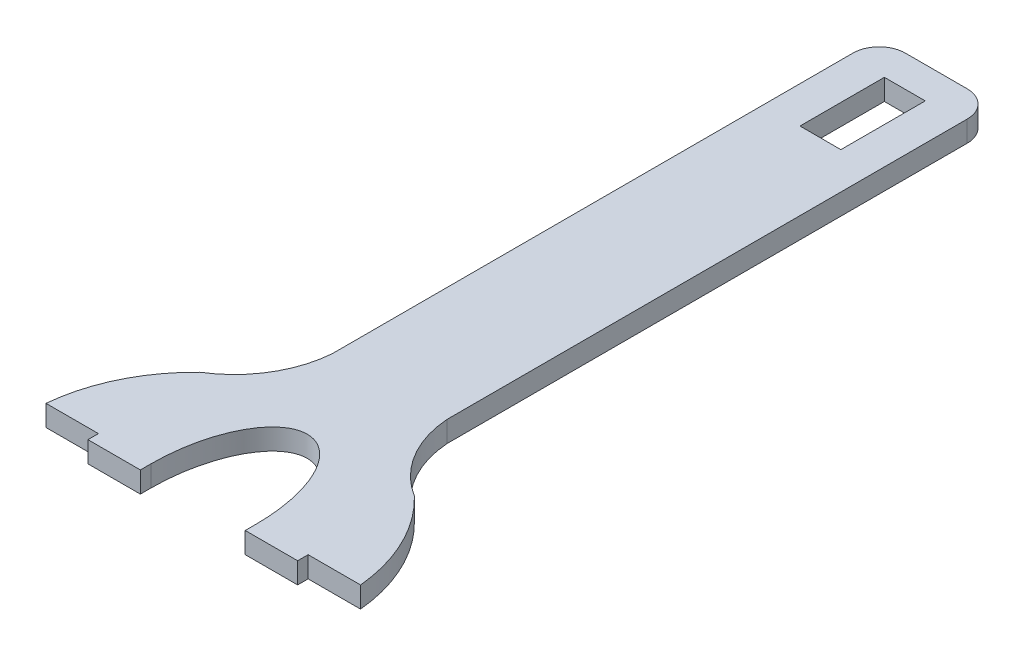
from build123d import *

# Parameters (mm, degrees)
BOSS_EXTRUDE1_DEPTH = 10.16
SKETCH2_W           = 19.812
SKETCH2_H           = 40.894
CUT_EXTRUDE1_DEPTH  = 11.1600001


with BuildPart() as part:
    # Sketch1 → Boss-Extrude1 (new body)
    with BuildSketch(Plane(origin=(0, 0, 0), x_dir=(1, 0, 0), z_dir=(0, 1, 0))):
        with BuildLine():
            Line((0, 0), (25.4, 0))
            Line((25.4, 0), (25.4, -5.08))
            Line((25.4, -5.08), (50.8, -5.08))
            Line((50.8, -5.08), (50.8, 0))
            add(Edge.make_bspline(
                [(101.6, 0), (101.6, 50.34872209), (76.2, 50.34872209), (50.8, 50.34872209), (50.8, 0)],
                knots=[4.71238898, 4.71238898, 4.71238898, 6.283185307, 6.283185307, 7.853981634, 7.853981634, 7.853981634], degree=2, weights=[1, 0.707106781, 1, 0.707106781, 1]))
            Line((101.6, 0), (101.6, -5.08))
            Line((101.6, -5.08), (127, -5.08))
            Line((127, -5.08), (127, 0))
            Line((127, 0), (152.4, 0))
            ThreePointArc((152.4, 0), (144.794312609, 27.353399459), (128.142883849, 50.34872209))
            ThreePointArc((128.142883849, 50.34872209), (111.214894118, 67.437985679), (103.885767699, 90.348325535))
            Line((103.885767699, 90.348325535), (103.885767699, 342.44872209))
            ThreePointArc((103.885767699, 342.44872209), (100.16602382, 351.428978211), (91.185767699, 355.14872209))
            Line((91.185767699, 355.14872209), (61.214232301, 355.14872209))
            ThreePointArc((61.214232301, 355.14872209), (52.23397618, 351.428978211), (48.514232301, 342.44872209))
            Line((48.514232301, 342.44872209), (48.514232301, 90.348325535))
            ThreePointArc((48.514232301, 90.348325535), (41.185105882, 67.437985679), (24.257116151, 50.34872209))
            ThreePointArc((24.257116151, 50.34872209), (7.605687391, 27.353399459), (0, 0))
        make_face()
    extrude(amount=BOSS_EXTRUDE1_DEPTH)

    # Sketch2 → Cut-Extrude1 (cut, through all)
    with BuildSketch(Plane(origin=(0, 10.16, 0), x_dir=(1, 0, 0), z_dir=(0, 1, 0))):
        with Locations((76.200232301, 319.46172209)):
            Rectangle(SKETCH2_W, SKETCH2_H)
    extrude(amount=-CUT_EXTRUDE1_DEPTH, mode=Mode.SUBTRACT)


solid = part.part
